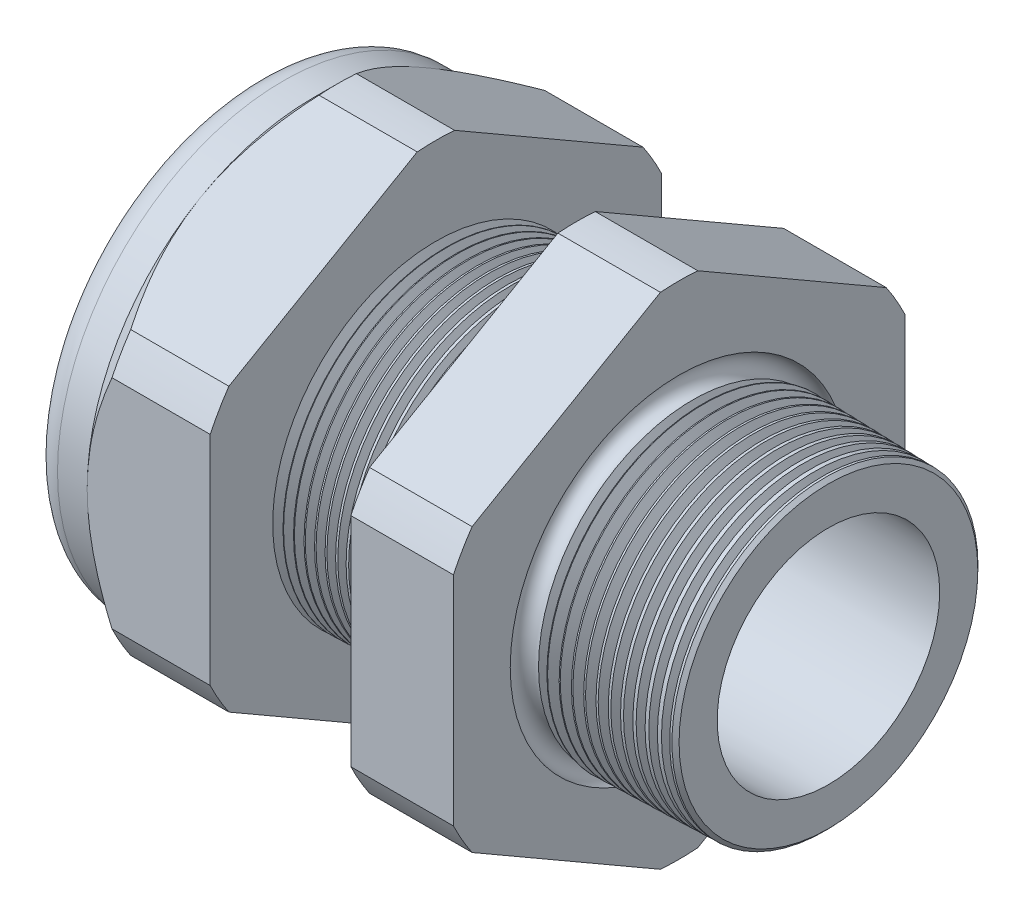
from build123d import *

# Parameters (mm, degrees)
SKETCH12_OUTSIDE_W = 88.514
SKETCH12_OUTSIDE_H = 88.514
CUT_EXTRUDE2_DEPTH = 38.71
FILLET4_R          = 2.032
SKETCH19_OUTSIDE_W = 55.962
SKETCH19_OUTSIDE_H = 59.594
SKETCH19_OUTSIDE_R = 16.51
CUT_EXTRUDE3_DEPTH = 3.99796
CUT_EXTRUDE3_DRAFT = -45
CHAMFER1_SIZE      = 0.260919487
CHAMFER1_SIZE2     = 0.254
SKETCH21_R         = 9.017
PLUG_DEPTH         = 8.89
SKETCH22_R         = 8.763
CUT_EXTRUDE4_DEPTH = 0.508
SKETCH27_R         = 2.54
PLUGHOLES_DEPTH    = 42.402
CIRPATTERN1_COUNT  = 4
LPATTERN1_COUNT    = 14
LPATTERN1_PITCH    = 0.762
LPATTERN2_COUNT    = 12
LPATTERN2_PITCH    = 0.889
SKETCH32_R         = 0.889


with BuildPart() as part:
    # Sketch10 → Revolve2 (revolve)
    with BuildSketch(Plane.XY, mode=Mode.PRIVATE) as revolve2_sk:
        Polygon((-38.862, 9.017), (-25.662, 9.017), (3.048, 8.138202192), (3.048, 11.186202192), (-7.874, 11.472204827), (-7.874, 33.02), (-15.374, 33.02), (-15.374, 11.668599239), (-25.662, 11.938), (-25.662, 33.02), (-34.662, 33.02), (-34.662, 16.51), (-38.862, 16.51), align=None)
    revolve(revolve2_sk.sketch.rotate(Axis((0, 0, 0), (-1, 0, 0)), 90), axis=Axis((0, 0, 0), (-1, 0, 0)))  # turned: the seam where the file's is

    # Sketch12 outside → Cut-Extrude2 (cut, through all)
    with BuildSketch(Plane.ZY.offset(34.662)):
        Rectangle(SKETCH12_OUTSIDE_W, SKETCH12_OUTSIDE_H)
        with BuildLine():
            Line((-1.366648898, 18.27507078), (-15.143351102, 10.321088053))
            ThreePointArc((-15.143351102, 10.321088053), (-15.870868152, 9.16305), (-16.51, 7.953982726))
            Line((-16.51, 7.953982726), (-16.51, -7.953982726))
            ThreePointArc((-16.51, -7.953982726), (-15.870868152, -9.16305), (-15.143351102, -10.321088053))
            Line((-15.143351102, -10.321088053), (-1.366648898, -18.27507078))
            ThreePointArc((-1.366648898, -18.27507078), (0, -18.3261), (1.366648898, -18.27507078))
            Line((1.366648898, -18.27507078), (15.143351102, -10.321088053))
            ThreePointArc((15.143351102, -10.321088053), (15.870868152, -9.16305), (16.51, -7.953982726))
            Line((16.51, -7.953982726), (16.51, 7.953982726))
            ThreePointArc((16.51, 7.953982726), (15.870868152, 9.16305), (15.143351102, 10.321088053))
            Line((15.143351102, 10.321088053), (1.366648898, 18.27507078))
            ThreePointArc((1.366648898, 18.27507078), (0, 18.3261), (-1.366648898, 18.27507078))
        make_face(mode=Mode.SUBTRACT)
    extrude(amount=-CUT_EXTRUDE2_DEPTH, mode=Mode.SUBTRACT)

    # Fillet4
    fillet4_edges = [part.edges().sort_by_distance(p)[0] for p in [
        (-38.862, 0, 16.51),
    ]]
    fillet(fillet4_edges, radius=FILLET4_R)


with BuildPart() as cut_extrude3_tool:
    # Sketch19 outside → Cut-Extrude3 (with draft: the straight prism first)
    with BuildSketch(Plane.ZY.offset(34.662)):
        Rectangle(SKETCH19_OUTSIDE_W, SKETCH19_OUTSIDE_H)
        Circle(SKETCH19_OUTSIDE_R, mode=Mode.SUBTRACT)
    extrude(amount=-CUT_EXTRUDE3_DEPTH)
    # Cut-Extrude3: the draft: its side faces are tilted about the plane it starts from
    cut_extrude3_sides = [cut_extrude3_tool.faces().sort_by_distance(p)[0] for p in [
        (-32.66302, -29.797, 0),
        (-32.66302, 0, 27.981),
        (-32.66302, 29.797, 0),
        (-32.66302, 0, -27.981),
        (-32.66302, 0, -16.51),
    ]]
    draft(cut_extrude3_sides, Plane.ZY.offset(34.662), CUT_EXTRUDE3_DRAFT)


with BuildPart() as part_1:
    add(part.part)

    # Cut-Extrude3: cut by cut_extrude3_tool
    add(cut_extrude3_tool.part, mode=Mode.SUBTRACT)

    # Chamfer1
    chamfer1_edges = [part_1.edges().sort_by_distance(p)[0] for p in [
        (3.048, 0, 11.186202192),
    ]]
    chamfer1_side = [part_1.faces().sort_by_distance(p)[0] for p in [
        (3.048, 0, 8.454595769),
    ]]
    chamfer(chamfer1_edges, length=CHAMFER1_SIZE, length2=CHAMFER1_SIZE2, reference=chamfer1_side[0])

    # Sketch29 → Cut-Revolve1 (revolve, cut)
    with BuildSketch(Plane.XY, mode=Mode.PRIVATE) as cut_revolve1_sk:
        Polygon((-25.662, 11.938), (-24.929016419, 11.918806149), (-25.312130572, 11.293620673), align=None)
    cut_revolve1 = revolve(cut_revolve1_sk.sketch.rotate(Axis((0, 0, 0), (-1, 0, 0)), 90), axis=Axis((0, 0, 0), (-1, 0, 0)), mode=Mode.SUBTRACT)  # turned: the seam where the file's is

    # LPattern1: Cut-Revolve1 ×14
    with Locations(*[(i * LPATTERN1_PITCH, 0, 0) for i in range(1, LPATTERN1_COUNT)]):
        add(cut_revolve1, mode=Mode.SUBTRACT)

    # Sketch30 → Cut-Revolve2 (revolve, cut)
    with BuildSketch(Plane.XY, mode=Mode.PRIVATE) as cut_revolve2_sk:
        Polygon((-7.874, 11.472204827), (-6.994419703, 11.449172206), (-7.454156686, 10.698949635), align=None)
    cut_revolve2 = revolve(cut_revolve2_sk.sketch.rotate(Axis((0, 0, 0), (-1, 0, 0)), 270), axis=Axis((0, 0, 0), (-1, 0, 0)), mode=Mode.SUBTRACT)  # turned: the seam where the file's is

    # LPattern2: Cut-Revolve2 ×12
    with Locations(*[(i * LPATTERN2_PITCH, 0, 0) for i in range(1, LPATTERN2_COUNT)]):
        add(cut_revolve2, mode=Mode.SUBTRACT)

    # Sketch32 → Cut-Revolve3 (revolve, cut)
    with BuildSketch(Plane.XY, mode=Mode.PRIVATE) as cut_revolve3_sk:
        with Locations((-7.747, 11.472204827)):
            Circle(SKETCH32_R)
    revolve(cut_revolve3_sk.sketch.rotate(Axis((0, 0, 0), (-1, 0, 0)), 270), axis=Axis((0, 0, 0), (-1, 0, 0)), mode=Mode.SUBTRACT)  # turned: the seam where the file's is


with BuildPart() as body_2:
    # Sketch21 → plug (new body)
    with BuildSketch(Plane.ZY.offset(38.862)):
        Circle(SKETCH21_R)
    extrude(amount=-PLUG_DEPTH)

    # Sketch22 → Cut-Extrude4 (cut)
    with BuildSketch(Plane.ZY.offset(38.862)):
        Circle(SKETCH22_R)
    extrude(amount=-CUT_EXTRUDE4_DEPTH, mode=Mode.SUBTRACT)

    # Sketch27 → plugholes (cut, through all)
    with BuildSketch(Plane.ZY.offset(38.354)):
        with Locations((-6.21284, 0)):
            Circle(SKETCH27_R)
    plugholes = extrude(amount=-PLUGHOLES_DEPTH, mode=Mode.SUBTRACT)

    # CirPattern1: plugholes ×4 about axis
    cirpattern1_axis = Axis((0, 0, 0), (1, 0, 0))
    for i in range(1, CIRPATTERN1_COUNT):
        add(plugholes.rotate(cirpattern1_axis, i * 360 / CIRPATTERN1_COUNT), mode=Mode.SUBTRACT)


solid = Compound([part_1.part, body_2.part])
